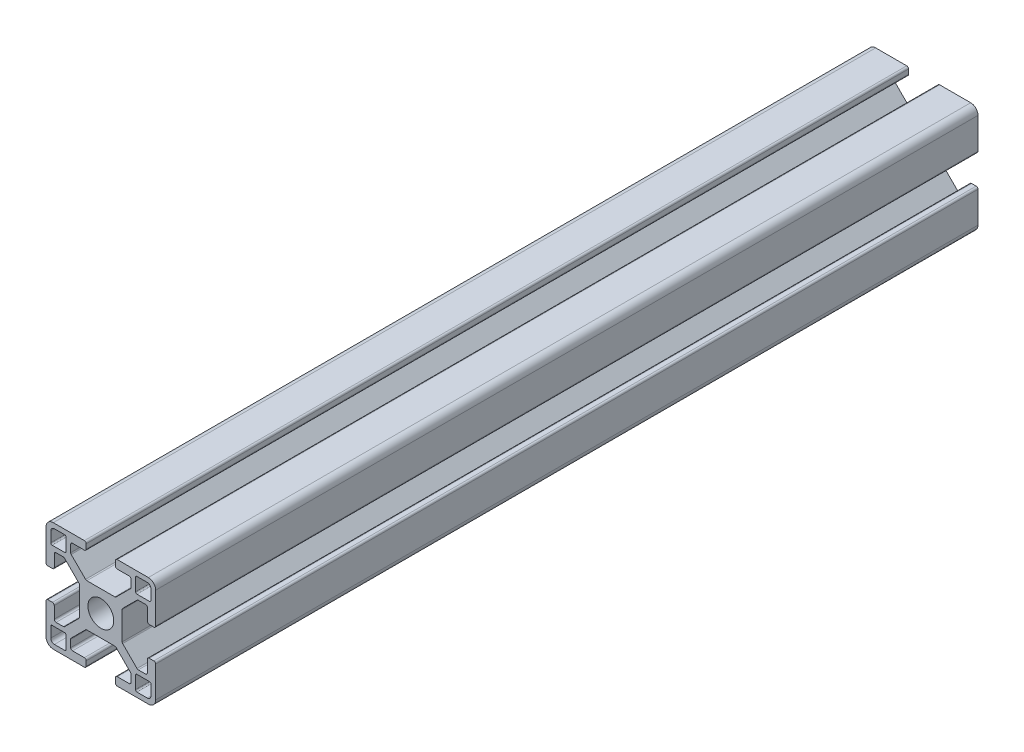
from build123d import *

# Parameters (mm, degrees)
SKETCH1_R           = 3.52998588
BOSS_EXTRUDE1_DEPTH = 112.5


with BuildPart() as part:
    # Sketch1 → Boss-Extrude1 (new body, symmetric)
    with BuildSketch(Plane.XY):
        with BuildLine():
            Line((14.49994, -4), (13.24247465, -4))
            ThreePointArc((13.24247465, -4), (12.88892126, -4.146446609), (12.74247465, -4.5))
            Line((12.74247465, -4.5), (12.74247465, -7.732519321))
            ThreePointArc((12.74247465, -7.732519321), (12.602449697, -8.097296796), (12.242781236, -8.249967))
            Line((12.242781236, -8.249967), (10.260188032, -8.249967))
            ThreePointArc((10.260188032, -8.249967), (10.068847082, -8.211906919), (9.906636056, -8.103520976))
            Line((9.906636056, -8.103520976), (5.981117769, -4.178002689))
            ThreePointArc((5.981117769, -4.178002689), (5.872731827, -4.015791664), (5.834671745, -3.824450713))
            Line((5.834671745, -3.824450713), (5.834671745, -1.01249595))
            Line((5.834671745, -1.01249595), (5.834671745, 0.88749645))
            Line((5.834671745, 0.88749645), (5.834671745, 3.824450713))
            ThreePointArc((5.834671745, 3.824450713), (5.872731827, 4.015791664), (5.981117769, 4.178002689))
            Line((5.981117769, 4.178002689), (9.906636056, 8.103520976))
            ThreePointArc((9.906636056, 8.103520976), (10.068847082, 8.211906919), (10.260188032, 8.249967))
            Line((10.260188032, 8.249967), (12.242781236, 8.249967))
            ThreePointArc((12.242781236, 8.249967), (12.602449697, 8.097296796), (12.74247465, 7.732519321))
            Line((12.74247465, 7.732519321), (12.74247465, 4.5))
            ThreePointArc((12.74247465, 4.5), (12.88892126, 4.146446609), (13.24247465, 4))
            Line((13.24247465, 4), (14.49994, 4))
            ThreePointArc((14.49994, 4), (14.853493391, 4.146446609), (14.99994, 4.5))
            Line((14.99994, 4.5), (14.99994, 12.999948))
            ThreePointArc((14.99994, 12.999948), (14.414155906, 14.414155906), (12.999948, 14.99994))
            Line((12.999948, 14.99994), (4.5, 14.99994))
            ThreePointArc((4.5, 14.99994), (4.146446609, 14.853493391), (4, 14.49994))
            Line((4, 14.49994), (4, 13.24247465))
            ThreePointArc((4, 13.24247465), (4.146446609, 12.88892126), (4.5, 12.74247465))
            Line((4.5, 12.74247465), (7.732519321, 12.74247465))
            ThreePointArc((7.732519321, 12.74247465), (8.097296796, 12.602449697), (8.249967, 12.242781236))
            Line((8.249967, 12.242781236), (8.249967, 10.260188032))
            ThreePointArc((8.249967, 10.260188032), (8.211906919, 10.068847082), (8.103520976, 9.906636056))
            Line((8.103520976, 9.906636056), (4.178002689, 5.981117769))
            ThreePointArc((4.178002689, 5.981117769), (4.015791664, 5.872731827), (3.824450713, 5.834671745))
            Line((3.824450713, 5.834671745), (0.9499962, 5.834671745))
            Line((0.9499962, 5.834671745), (-0.9499962, 5.834671745))
            Line((-0.9499962, 5.834671745), (-3.824450713, 5.834671745))
            ThreePointArc((-3.824450713, 5.834671745), (-4.015791664, 5.872731827), (-4.178002689, 5.981117769))
            Line((-4.178002689, 5.981117769), (-8.103520976, 9.906636056))
            ThreePointArc((-8.103520976, 9.906636056), (-8.211906919, 10.068847082), (-8.249967, 10.260188032))
            Line((-8.249967, 10.260188032), (-8.249967, 12.242781236))
            ThreePointArc((-8.249967, 12.242781236), (-8.097296796, 12.602449697), (-7.732519321, 12.74247465))
            Line((-7.732519321, 12.74247465), (-4.5, 12.74247465))
            ThreePointArc((-4.5, 12.74247465), (-4.146446609, 12.88892126), (-4, 13.24247465))
            Line((-4, 13.24247465), (-4, 14.49994))
            ThreePointArc((-4, 14.49994), (-4.146446609, 14.853493391), (-4.5, 14.99994))
            Line((-4.5, 14.99994), (-12.999948, 14.99994))
            ThreePointArc((-12.999948, 14.99994), (-14.414155906, 14.414155906), (-14.99994, 12.999948))
            Line((-14.99994, 12.999948), (-14.99994, 4.5))
            ThreePointArc((-14.99994, 4.5), (-14.853493391, 4.146446609), (-14.49994, 4))
            Line((-14.49994, 4), (-13.24247465, 4))
            ThreePointArc((-13.24247465, 4), (-12.88892126, 4.146446609), (-12.74247465, 4.5))
            Line((-12.74247465, 4.5), (-12.74247465, 7.732519321))
            ThreePointArc((-12.74247465, 7.732519321), (-12.602449697, 8.097296796), (-12.242781236, 8.249967))
            Line((-12.242781236, 8.249967), (-10.260188032, 8.249967))
            ThreePointArc((-10.260188032, 8.249967), (-10.068847082, 8.211906919), (-9.906636056, 8.103520976))
            Line((-9.906636056, 8.103520976), (-5.981117769, 4.178002689))
            ThreePointArc((-5.981117769, 4.178002689), (-5.872731827, 4.015791664), (-5.834671745, 3.824450713))
            Line((-5.834671745, 3.824450713), (-5.834671745, 0.88749645))
            Line((-5.834671745, 0.88749645), (-5.834671745, -1.01249595))
            Line((-5.834671745, -1.01249595), (-5.834671745, -3.824450713))
            ThreePointArc((-5.834671745, -3.824450713), (-5.872731827, -4.015791664), (-5.981117769, -4.178002689))
            Line((-5.981117769, -4.178002689), (-9.906636056, -8.103520976))
            ThreePointArc((-9.906636056, -8.103520976), (-10.068847082, -8.211906919), (-10.260188032, -8.249967))
            Line((-10.260188032, -8.249967), (-12.242781236, -8.249967))
            ThreePointArc((-12.242781236, -8.249967), (-12.602449697, -8.097296796), (-12.74247465, -7.732519321))
            Line((-12.74247465, -7.732519321), (-12.74247465, -4.5))
            ThreePointArc((-12.74247465, -4.5), (-12.88892126, -4.146446609), (-13.24247465, -4))
            Line((-13.24247465, -4), (-14.49994, -4))
            ThreePointArc((-14.49994, -4), (-14.853493391, -4.146446609), (-14.99994, -4.5))
            Line((-14.99994, -4.5), (-14.99994, -12.999948))
            ThreePointArc((-14.99994, -12.999948), (-14.414155906, -14.414155906), (-12.999948, -14.99994))
            Line((-12.999948, -14.99994), (-4.5, -14.99994))
            ThreePointArc((-4.5, -14.99994), (-4.146446609, -14.853493391), (-4, -14.49994))
            Line((-4, -14.49994), (-4, -13.24247465))
            ThreePointArc((-4, -13.24247465), (-4.146446609, -12.88892126), (-4.5, -12.74247465))
            Line((-4.5, -12.74247465), (-7.732519321, -12.74247465))
            ThreePointArc((-7.732519321, -12.74247465), (-8.097296796, -12.602449697), (-8.249967, -12.242781236))
            Line((-8.249967, -12.242781236), (-8.249967, -10.260188032))
            ThreePointArc((-8.249967, -10.260188032), (-8.211906919, -10.068847082), (-8.103520976, -9.906636056))
            Line((-8.103520976, -9.906636056), (-4.178002689, -5.981117769))
            ThreePointArc((-4.178002689, -5.981117769), (-4.015791664, -5.872731827), (-3.824450713, -5.834671745))
            Line((-3.824450713, -5.834671745), (-0.9499962, -5.834671745))
            Line((-0.9499962, -5.834671745), (0.9499962, -5.834671745))
            Line((0.9499962, -5.834671745), (3.824450713, -5.834671745))
            ThreePointArc((3.824450713, -5.834671745), (4.015791664, -5.872731827), (4.178002689, -5.981117769))
            Line((4.178002689, -5.981117769), (8.103520976, -9.906636056))
            ThreePointArc((8.103520976, -9.906636056), (8.211906919, -10.068847082), (8.249967, -10.260188032))
            Line((8.249967, -10.260188032), (8.249967, -12.242781236))
            ThreePointArc((8.249967, -12.242781236), (8.097296796, -12.602449697), (7.732519321, -12.74247465))
            Line((7.732519321, -12.74247465), (4.5, -12.74247465))
            ThreePointArc((4.5, -12.74247465), (4.146446609, -12.88892126), (4, -13.24247465))
            Line((4, -13.24247465), (4, -14.49994))
            ThreePointArc((4, -14.49994), (4.146446609, -14.853493391), (4.5, -14.99994))
            Line((4.5, -14.99994), (12.999948, -14.99994))
            ThreePointArc((12.999948, -14.99994), (14.414155906, -14.414155906), (14.99994, -12.999948))
            Line((14.99994, -12.999948), (14.99994, -4.5))
            ThreePointArc((14.99994, -4.5), (14.853493391, -4.146446609), (14.49994, -4))
        make_face()
        Circle(SKETCH1_R, mode=Mode.SUBTRACT)
        with BuildLine():
            Line((-12.6999492, -13.6999452), (-9.880960476, -13.6999452))
            ThreePointArc((-9.880960476, -13.6999452), (-9.61155387, -13.58835333), (-9.499962, -13.318946724))
            Line((-9.499962, -13.318946724), (-9.499962, -9.87996048))
            ThreePointArc((-9.499962, -9.87996048), (-9.611260978, -9.611260978), (-9.87996048, -9.499962))
            Line((-9.87996048, -9.499962), (-13.318946724, -9.499962))
            ThreePointArc((-13.318946724, -9.499962), (-13.58835333, -9.61155387), (-13.6999452, -9.880960476))
            Line((-13.6999452, -9.880960476), (-13.6999452, -12.6999492))
            ThreePointArc((-13.6999452, -12.6999492), (-13.407053153, -13.407053153), (-12.6999492, -13.6999452))
        make_face(mode=Mode.SUBTRACT)
        with BuildLine():
            Line((13.6999452, -12.6999492), (13.6999452, -9.880960476))
            ThreePointArc((13.6999452, -9.880960476), (13.58835333, -9.61155387), (13.318946724, -9.499962))
            Line((13.318946724, -9.499962), (9.87996048, -9.499962))
            ThreePointArc((9.87996048, -9.499962), (9.611260978, -9.611260978), (9.499962, -9.87996048))
            Line((9.499962, -9.87996048), (9.499962, -13.318946724))
            ThreePointArc((9.499962, -13.318946724), (9.61155387, -13.58835333), (9.880960476, -13.6999452))
            Line((9.880960476, -13.6999452), (12.6999492, -13.6999452))
            ThreePointArc((12.6999492, -13.6999452), (13.407053153, -13.407053153), (13.6999452, -12.6999492))
        make_face(mode=Mode.SUBTRACT)
        with BuildLine():
            Line((9.87996048, 9.499962), (13.318946724, 9.499962))
            ThreePointArc((13.318946724, 9.499962), (13.58835333, 9.61155387), (13.6999452, 9.880960476))
            Line((13.6999452, 9.880960476), (13.6999452, 12.6999492))
            ThreePointArc((13.6999452, 12.6999492), (13.407053153, 13.407053153), (12.6999492, 13.6999452))
            Line((12.6999492, 13.6999452), (9.880960476, 13.6999452))
            ThreePointArc((9.880960476, 13.6999452), (9.61155387, 13.58835333), (9.499962, 13.318946724))
            Line((9.499962, 13.318946724), (9.499962, 9.87996048))
            ThreePointArc((9.499962, 9.87996048), (9.611260978, 9.611260978), (9.87996048, 9.499962))
        make_face(mode=Mode.SUBTRACT)
        with BuildLine():
            Line((-13.6999452, 12.6999492), (-13.6999452, 9.880960476))
            ThreePointArc((-13.6999452, 9.880960476), (-13.58835333, 9.61155387), (-13.318946724, 9.499962))
            Line((-13.318946724, 9.499962), (-9.87996048, 9.499962))
            ThreePointArc((-9.87996048, 9.499962), (-9.611260978, 9.611260978), (-9.499962, 9.87996048))
            Line((-9.499962, 9.87996048), (-9.499962, 13.318946724))
            ThreePointArc((-9.499962, 13.318946724), (-9.61155387, 13.58835333), (-9.880960476, 13.6999452))
            Line((-9.880960476, 13.6999452), (-12.6999492, 13.6999452))
            ThreePointArc((-12.6999492, 13.6999452), (-13.407053153, 13.407053153), (-13.6999452, 12.6999492))
        make_face(mode=Mode.SUBTRACT)
    extrude(amount=BOSS_EXTRUDE1_DEPTH, both=True)


solid = part.part
